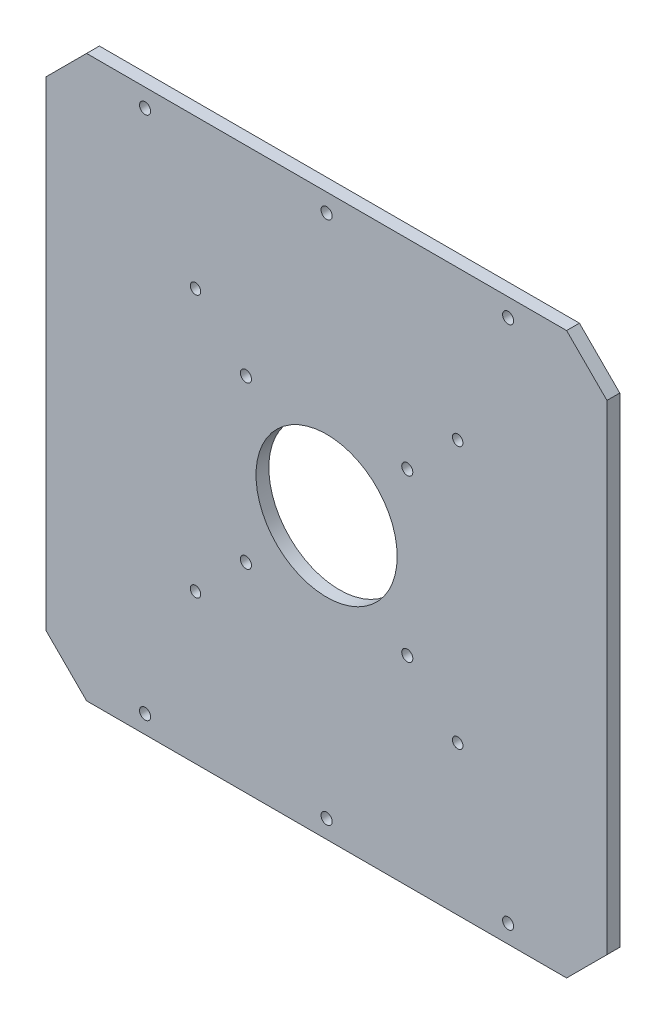
from build123d import *

# Parameters (mm, degrees)
SKETCH1_W           = 278
SKETCH1_H           = 278
BOSS_EXTRUDE1_DEPTH = 6.35
SKETCH2_R           = 35
SKETCH2_R_2         = 2.75
CUT_EXTRUDE1_DEPTH  = 7.35
CHAMFER1_SIZE       = 20
SKETCH4_R           = 2.75
CUT_EXTRUDE2_DEPTH  = 76.2
SKETCH6_R           = 2.6
CUT_EXTRUDE4_DEPTH  = 7.35


with BuildPart() as part:
    # Sketch1 → Boss-Extrude1 (new body)
    with BuildSketch(Plane.XY):
        Rectangle(SKETCH1_W, SKETCH1_H)
    extrude(amount=BOSS_EXTRUDE1_DEPTH)

    # Sketch2 → Cut-Extrude1 (cut, through all)
    with BuildSketch(Plane.XY.offset(6.35)):
        Circle(SKETCH2_R)
        with Locations((-40, 40)):
            Circle(SKETCH2_R_2)
        with Locations((40, 40)):
            Circle(SKETCH2_R_2)
        with Locations((40, -40)):
            Circle(SKETCH2_R_2)
        with Locations((-40, -40)):
            Circle(SKETCH2_R_2)
    extrude(amount=-CUT_EXTRUDE1_DEPTH, mode=Mode.SUBTRACT)

    # Chamfer1
    chamfer1_edges = [part.edges().sort_by_distance(p)[0] for p in [
        (-139, 139, 3.175),
        (139, 139, 3.175),
        (139, -139, 3.175),
        (-139, -139, 3.175),
    ]]
    chamfer(chamfer1_edges, length=CHAMFER1_SIZE)

    # Sketch4 → Cut-Extrude2 (cut)
    with BuildSketch(Plane.XY.offset(6.35)):
        with Locations((-90, 130)):
            Circle(SKETCH4_R)
        with Locations((0, 130)):
            Circle(SKETCH4_R)
        with Locations((90, 130)):
            Circle(SKETCH4_R)
        with Locations((90, -130)):
            Circle(SKETCH4_R)
        with Locations((0, -130)):
            Circle(SKETCH4_R)
        with Locations((-90, -130)):
            Circle(SKETCH4_R)
    extrude(amount=-CUT_EXTRUDE2_DEPTH, mode=Mode.SUBTRACT)

    # Sketch6 → Cut-Extrude4 (cut, through all)
    with BuildSketch(Plane(origin=(0, 0, 0), x_dir=(-1, 0, 0), z_dir=(0, 0, -1))):
        with Locations((65, 65)):
            Circle(SKETCH6_R)
        with Locations((65, -65)):
            Circle(SKETCH6_R)
        with Locations((-65, -65)):
            Circle(SKETCH6_R)
        with Locations((-65, 65)):
            Circle(SKETCH6_R)
    extrude(amount=-CUT_EXTRUDE4_DEPTH, mode=Mode.SUBTRACT)


solid = part.part
